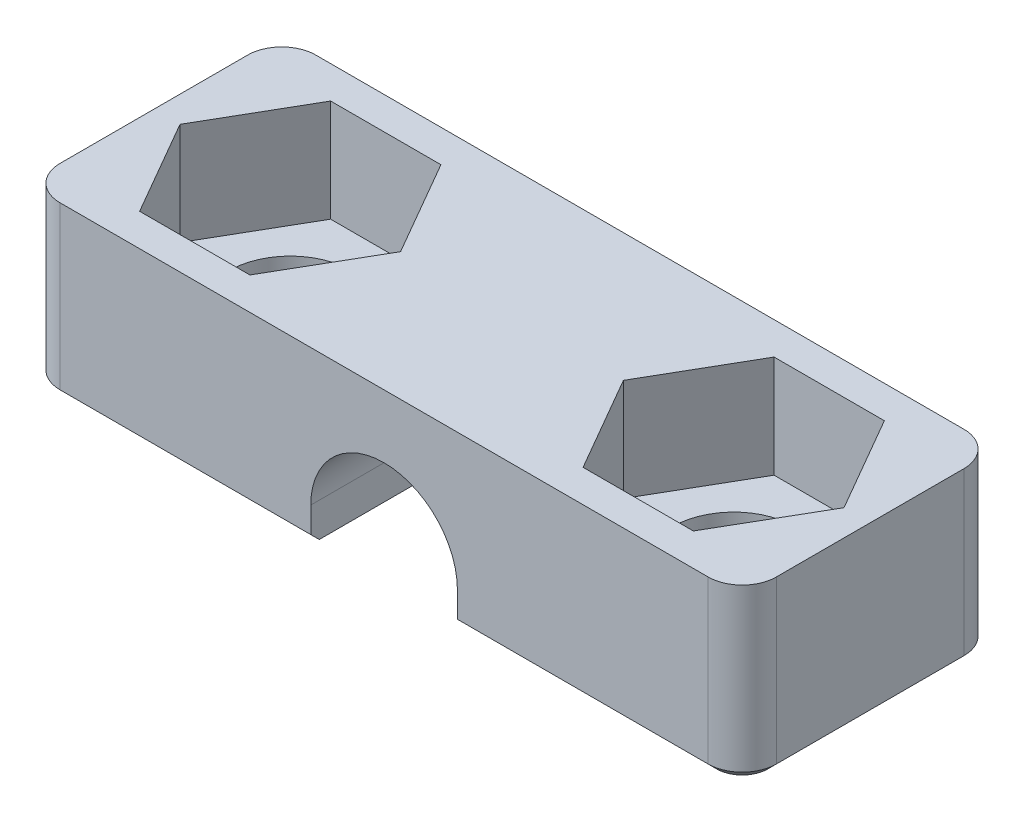
from build123d import *

# Parameters (mm, degrees)
EXTRUDE1_DEPTH = 7.5
SKETCH2_R      = 1.8
EXTRUDE2_DEPTH = 14.838352503
SKETCH_R       = 1.8
EXTRUDE3_DEPTH = 3
FILLET1_R      = 1
CHAMFER1_SIZE  = 0.25


with BuildPart() as part:
    # Sketch1 → Extrude1 (new body)
    with BuildSketch(Plane.XY):
        with BuildLine():
            Line((-2.15, 0), (-2.15, 1))
            ThreePointArc((-2.15, 1), (0, 3.15), (2.15, 1))
            Line((2.15, 1), (2.15, 0))
            Line((2.15, 0), (10.5, 0))
            Line((10.5, 0), (10.5, 5))
            Line((10.5, 5), (-10.5, 5))
            Line((-10.5, 5), (-10.5, 0))
            Line((-10.5, 0), (-2.15, 0))
        make_face()
    extrude(amount=EXTRUDE1_DEPTH)

    # Sketch2 → Extrude2 (cut, through all)
    with BuildSketch(Plane(origin=(0, 5, 0), x_dir=(1, 0, 0), z_dir=(0, 1, 0))):
        with Locations((6.5, -3.75)):
            Circle(SKETCH2_R)
        with Locations((-6.5, -3.75)):
            Circle(SKETCH2_R)
    extrude(amount=-EXTRUDE2_DEPTH, mode=Mode.SUBTRACT)

    # Sketch → Extrude3 (cut)
    # profile 1 of 2: a face of its own
    with BuildSketch(Plane(origin=(0, 5, 0), x_dir=(1, 0, 0), z_dir=(0, 1, 0))):
        Polygon((-8.116580754, -6.55), (-9.733161507, -3.75), (-8.116580754, -0.95), (-4.883419246, -0.95), (-3.266838493, -3.75), (-4.883419246, -6.55), align=None)
        with Locations((-6.5, -3.75)):
            Circle(SKETCH_R, mode=Mode.SUBTRACT)
    # profile 2 of 2: a face of its own
    with BuildSketch(Plane(origin=(0, 5, 0), x_dir=(1, 0, 0), z_dir=(0, 1, 0))):
        Polygon((9.733161507, -3.75), (8.116580754, -0.95), (4.883419246, -0.95), (3.266838493, -3.75), (4.883419246, -6.55), (8.116580754, -6.55), align=None)
        with Locations((6.5, -3.75)):
            Circle(SKETCH_R, mode=Mode.SUBTRACT)
    extrude(amount=-EXTRUDE3_DEPTH, mode=Mode.SUBTRACT)

    # Fillet1
    fillet1_edges = [part.edges().sort_by_distance(p)[0] for p in [
        (10.5, 2.5, 0),
        (10.5, 2.5, 7.5),
        (-10.5, 2.5, 0),
        (-10.5, 2.5, 7.5),
    ]]
    fillet(fillet1_edges, radius=FILLET1_R)

    # Chamfer1
    chamfer1_edges = [part.edges().sort_by_distance(p)[0] for p in [
        (-8.3, 0, 3.75),
        (4.7, 0, 3.75),
        (5.825, 0, 0),
        (10.207106781, 0, 0.292893219),
        (10.5, 0, 3.75),
        (10.207106781, 0, 7.207106781),
        (5.825, 0, 7.5),
        (-5.825, 0, 0),
        (-10.207106781, 0, 0.292893219),
        (-10.5, 0, 3.75),
        (-10.207106781, 0, 7.207106781),
        (-5.825, 0, 7.5),
    ]]
    chamfer(chamfer1_edges, length=CHAMFER1_SIZE)


solid = part.part
